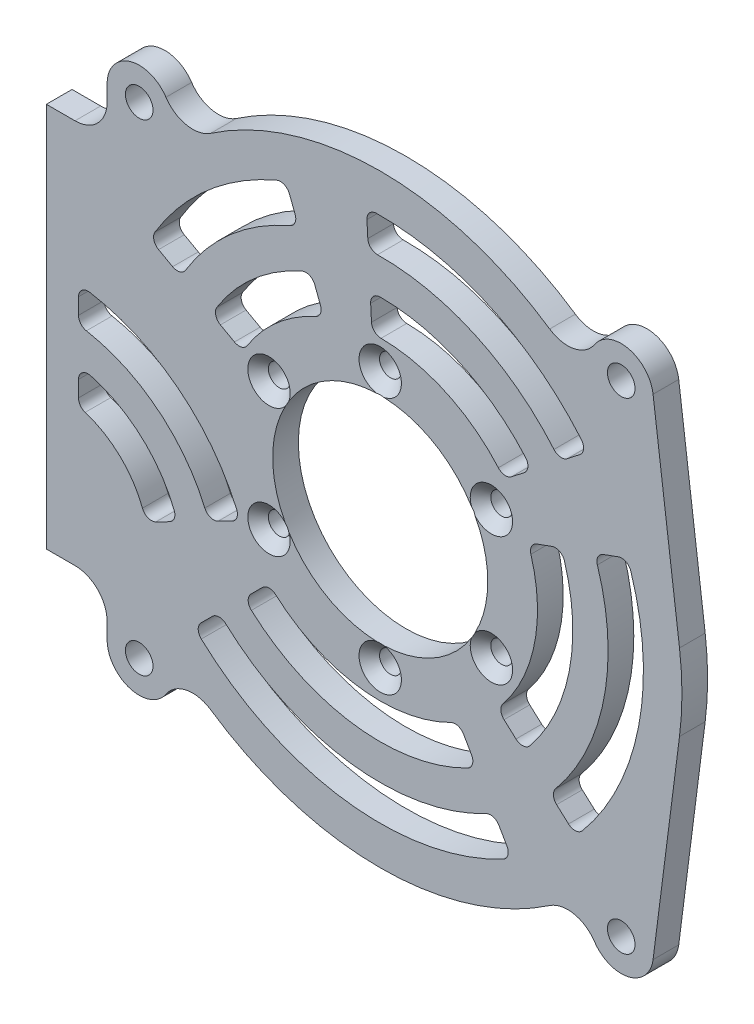
from build123d import *

# Parameters (mm, degrees)
SKETCH_1_R                = 2.15
EXTRUDE_1_DEPTH           = 4
SKETCH_2_R                = 16.75
SKETCH_2_R_2              = 1.65
CUT_EXTRUDE_1_DEPTH       = 10
CUT_EXTRUDE_2_DEPTH       = 10
FILLET_1_R                = 1.5
HOLE_WIZARD_1_D           = 3.4
HOLE_WIZARD_1_CSINK_D     = 6.6
HOLE_WIZARD_1_CSINK_ANGLE = 90


with BuildPart() as part:
    # 草图1 → 凸台-拉伸1 (new body)
    with BuildSketch(Plane.XY):
        with BuildLine():
            Line((-52, 30), (-52, 8.75))
            Line((-52, 8.75), (-52, -8.75))
            Line((-52, -8.75), (-52, -30))
            Line((-52, -30), (-47.54, -30))
            ThreePointArc((-47.54, -30), (-44.004466094, -31.464466094), (-42.54, -35))
            Line((-42.54, -35), (-42.54, -37.5))
            ThreePointArc((-42.54, -37.5), (-38.982425028, -42.287422066), (-33.372235985, -40.262198963))
            ThreePointArc((-33.372235985, -40.262198963), (-30.171244586, -38.118753147), (-26.396349665, -38.887436588))
            ThreePointArc((-26.396349665, -38.887436588), (0, -47), (26.396349665, -38.887436588))
            ThreePointArc((26.396349665, -38.887436588), (30.171244586, -38.118753147), (33.372235985, -40.262198963))
            ThreePointArc((33.372235985, -40.262198963), (38.674773042, -42.369526686), (42.499484755, -38.135225128))
            Line((42.499484755, -38.135225128), (46.619156699, -5.971116201))
            ThreePointArc((46.619156699, -5.971116201), (47, 0), (46.619156699, 5.971116201))
            Line((46.619156699, 5.971116201), (42.499484755, 38.135225128))
            ThreePointArc((42.499484755, 38.135225128), (38.674773042, 42.369526686), (33.372235985, 40.262198963))
            ThreePointArc((33.372235985, 40.262198963), (30.171244586, 38.118753147), (26.396349665, 38.887436588))
            ThreePointArc((26.396349665, 38.887436588), (0, 47), (-26.396349665, 38.887436588))
            ThreePointArc((-26.396349665, 38.887436588), (-30.171244586, 38.118753147), (-33.372235985, 40.262198963))
            ThreePointArc((-33.372235985, 40.262198963), (-38.982425028, 42.287422066), (-42.54, 37.5))
            Line((-42.54, 37.5), (-42.54, 35))
            ThreePointArc((-42.54, 35), (-44.004466094, 31.464466094), (-47.54, 30))
            Line((-47.54, 30), (-52, 30))
        make_face()
        with Locations((-37.54, -37.5)):
            Circle(SKETCH_1_R, mode=Mode.SUBTRACT)
        with Locations((37.54, -37.5)):
            Circle(SKETCH_1_R, mode=Mode.SUBTRACT)
        with Locations((-37.54, 37.5)):
            Circle(SKETCH_1_R, mode=Mode.SUBTRACT)
        with Locations((37.54, 37.5)):
            Circle(SKETCH_1_R, mode=Mode.SUBTRACT)
    extrude(amount=EXTRUDE_1_DEPTH)

    # 草图2 → 切除-拉伸1 (cut)
    with BuildSketch(Plane.XY.offset(4)):
        Circle(SKETCH_2_R)
        with Locations((0, 20)):
            Circle(SKETCH_2_R_2)
        with Locations((17.320508076, 10)):
            Circle(SKETCH_2_R_2)
        with Locations((17.320508076, -10)):
            Circle(SKETCH_2_R_2)
        with Locations((0, -20)):
            Circle(SKETCH_2_R_2)
        with Locations((-17.320508076, -10)):
            Circle(SKETCH_2_R_2)
        with Locations((-17.320508076, 10)):
            Circle(SKETCH_2_R_2)
    extrude(amount=-CUT_EXTRUDE_1_DEPTH, mode=Mode.SUBTRACT)

    # 草图3 → 切除-拉伸2 (cut)
    with BuildSketch(Plane.XY.offset(4)):
        with BuildLine():
            Line((-8.780014764, 22.872720449), (-10.751038486, 28.007412795))
            ThreePointArc((-10.751038486, 28.007412795), (-19.68177087, 22.641287407), (-26.238591214, 14.544288607))
            Line((-26.238591214, 14.544288607), (-21.428182825, 11.877835696))
            ThreePointArc((-21.428182825, 11.877835696), (-16.07344621, 18.490384715), (-8.780014764, 22.872720449))
        make_face()
        with BuildLine():
            Line((-1.282230928, 24.466423601), (-1.570078687, 29.958886043))
            ThreePointArc((-1.570078687, 29.958886043), (12.44079728, 27.298838126), (23.640322608, 18.46984426))
            Line((23.640322608, 18.46984426), (19.306263463, 15.083706145))
            ThreePointArc((19.306263463, 15.083706145), (10.159984445, 22.294051136), (-1.282230928, 24.466423601))
        make_face()
        with BuildLine():
            Line((23.022469209, 8.379493511), (28.190778624, 10.2606043))
            ThreePointArc((28.190778624, 10.2606043), (29.448815503, -5.724269861), (22.294344764, -20.073918191))
            Line((22.294344764, -20.073918191), (18.207048224, -16.393699856))
            ThreePointArc((18.207048224, -16.393699856), (24.049865994, -4.674820387), (23.022469209, 8.379493511))
        make_face()
        with BuildLine():
            Line((12.25, -21.217622393), (15, -25.980762114))
            ThreePointArc((15, -25.980762114), (-3.915785767, -29.743345841), (-21.213203436, -21.213203436))
            Line((-21.213203436, -21.213203436), (-17.324116139, -17.324116139))
            ThreePointArc((-17.324116139, -17.324116139), (-3.197891709, -24.290399104), (12.25, -21.217622393))
        make_face()
        with BuildLine():
            Line((-21.829659843, -11.122767244), (-26.730195726, -13.619714992))
            ThreePointArc((-26.730195726, -13.619714992), (-34.556729311, -2.576519476), (-47, 2.75))
            Line((-47, 2.75), (-47, 8.25))
            ThreePointArc((-47, 8.25), (-31.682987205, 2.113001428), (-21.829659843, -11.122767244))
        make_face()
        with BuildLine():
            Line((-12.722062209, 33.142105141), (-14.693085931, 38.276797486))
            ThreePointArc((-14.693085931, 38.276797486), (-26.898420189, 30.943092789), (-35.859407993, 19.87719443))
            Line((-35.859407993, 19.87719443), (-31.048999603, 17.210741519))
            ThreePointArc((-31.048999603, 17.210741519), (-23.290095529, 26.792190098), (-12.722062209, 33.142105141))
        make_face()
        with BuildLine():
            Line((-1.857926447, 35.451348484), (-2.145774206, 40.943810925))
            ThreePointArc((-2.145774206, 40.943810925), (17.002422949, 37.308412106), (32.308440898, 25.242120488))
            Line((32.308440898, 25.242120488), (27.974381753, 21.855982374))
            ThreePointArc((27.974381753, 21.855982374), (14.721610114, 32.303625116), (-1.857926447, 35.451348484))
        make_face()
        with BuildLine():
            Line((33.359088038, 12.141715088), (38.527397452, 14.022825876))
            ThreePointArc((38.527397452, 14.022825876), (40.246714521, -7.82316881), (30.468937845, -27.434354861))
            Line((30.468937845, -27.434354861), (26.381641304, -23.754136526))
            ThreePointArc((26.381641304, -23.754136526), (34.847765012, -6.773719336), (33.359088038, 12.141715088))
        make_face()
        with BuildLine():
            Line((17.75, -30.743901834), (20.5, -35.507041555))
            ThreePointArc((20.5, -35.507041555), (-5.351573881, -40.649239316), (-28.991378029, -28.991378029))
            Line((-28.991378029, -28.991378029), (-25.102290732, -25.102290732))
            ThreePointArc((-25.102290732, -25.102290732), (-4.633679824, -35.196292579), (17.75, -30.743901834))
        make_face()
        with BuildLine():
            Line((-31.630731609, -16.116662741), (-36.531267492, -18.613610489))
            ThreePointArc((-36.531267492, -18.613610489), (-40.304213522, -11.955561283), (-47, -8.25))
            Line((-47, -8.25), (-47, -2.75))
            ThreePointArc((-47, -2.75), (-37.430471416, -7.266040379), (-31.630731609, -16.116662741))
        make_face()
    extrude(amount=-CUT_EXTRUDE_2_DEPTH, mode=Mode.SUBTRACT)

    # 圆角1
    fillet_1_edges = [part.edges().sort_by_distance(p)[0] for p in [
        (-47, 8.25, 2),
        (-21.829659843, -11.122767244, 2),
        (-26.730195726, -13.619714992, 2),
        (-47, 2.75, 2),
        (-35.859407993, 19.87719443, 2),
        (-14.693085931, 38.276797486, 2),
        (-12.722062209, 33.142105141, 2),
        (-31.048999603, 17.210741519, 2),
        (-17.324116139, -17.324116139, 2),
        (12.25, -21.217622393, 2),
        (15, -25.980762114, 2),
        (-21.213203436, -21.213203436, 2),
        (20.5, -35.507041555, 2),
        (-28.991378029, -28.991378029, 2),
        (-25.102290732, -25.102290732, 2),
        (17.75, -30.743901834, 2),
        (-1.570078687, 29.958886043, 2),
        (23.640322608, 18.46984426, 2),
        (19.306263463, 15.083706145, 2),
        (-1.282230928, 24.466423601, 2),
        (26.381641304, -23.754136526, 2),
        (33.359088038, 12.141715088, 2),
        (38.527397452, 14.022825876, 2),
        (30.468937845, -27.434354861, 2),
        (27.974381753, 21.855982374, 2),
        (-1.857926447, 35.451348484, 2),
        (-2.145774206, 40.943810925, 2),
        (32.308440898, 25.242120488, 2),
        (-8.780014764, 22.872720449, 2),
        (-21.428182825, 11.877835696, 2),
        (-26.238591214, 14.544288607, 2),
        (-10.751038486, 28.007412795, 2),
        (-36.531267492, -18.613610489, 2),
        (-47, -8.25, 2),
        (-47, -2.75, 2),
        (-31.630731609, -16.116662741, 2),
        (28.190778624, 10.2606043, 2),
        (22.294344764, -20.073918191, 2),
        (18.207048224, -16.393699856, 2),
        (23.022469209, 8.379493511, 2),
    ]]
    fillet(fillet_1_edges, radius=FILLET_1_R)

    # 打孔尺寸(%根据十字)槽半沉头木螺钉的类型1 (through all)
    with Locations(Plane(origin=(-17.320508076, 10, 4), x_dir=(1, 0, 0), z_dir=(0, 0, 1))):
        with Locations((0, 0), (17.320508076, 10), (34.641016152, 0), (34.641016152, -20), (17.320508076, -30), (0, -20)):
            CounterSinkHole(HOLE_WIZARD_1_D / 2, HOLE_WIZARD_1_CSINK_D / 2, counter_sink_angle=HOLE_WIZARD_1_CSINK_ANGLE)


solid = part.part
